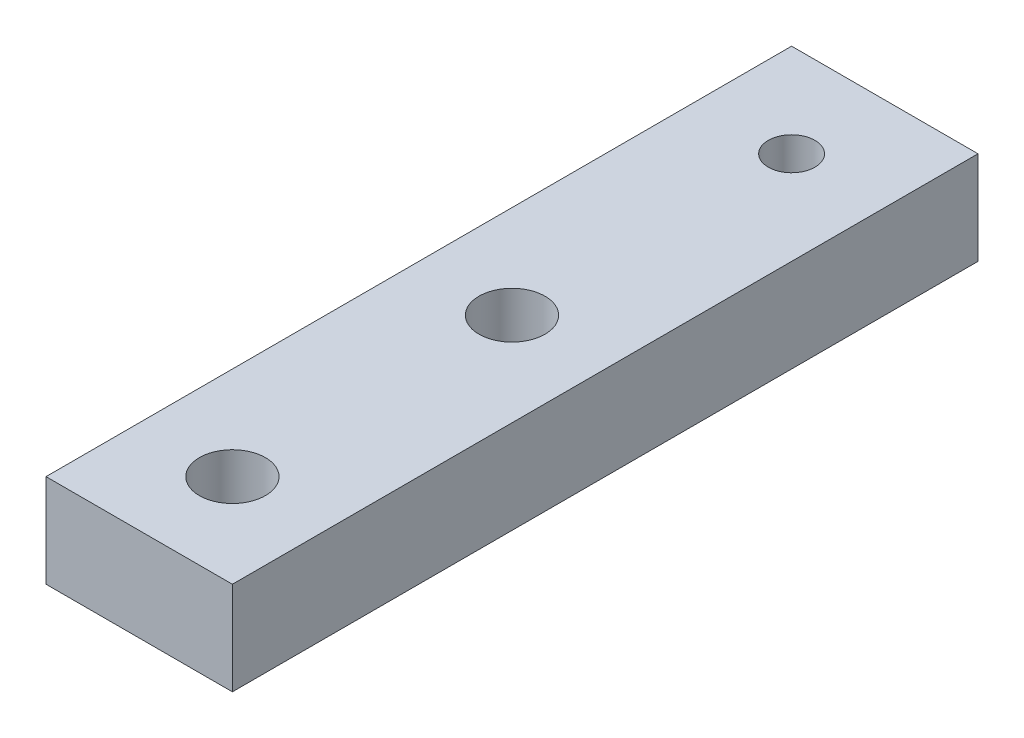
from build123d import *

# Parameters (mm, degrees)
SKETCH1_W             = 12.7
SKETCH1_H             = 50.8
BOSS_EXTRUDE1_DEPTH   = 6.35
SKETCH9_R             = 1.5875
CUT_EXTRUDE1_DEPTH    = 7.35
F_8_CLEARANCE_HOLE1_D = 4.4958


with BuildPart() as part:
    # Sketch1 → Boss-Extrude1 (new body)
    with BuildSketch(Plane(origin=(0, 0, 0), x_dir=(1, 0, 0), z_dir=(0, 1, 0))):
        with Locations((6.35, 25.4)):
            Rectangle(SKETCH1_W, SKETCH1_H)
    extrude(amount=BOSS_EXTRUDE1_DEPTH)

    # Sketch9 → Cut-Extrude1 (cut, through all)
    with BuildSketch(Plane(origin=(0, 6.35, 0), x_dir=(1, 0, 0), z_dir=(0, 1, 0))):
        with Locations(Location((6.35, 44.45, 0), (0, 0, 270))):  # turned: the seam where the file's is
            Circle(SKETCH9_R)
    extrude(amount=-CUT_EXTRUDE1_DEPTH, mode=Mode.SUBTRACT)

    # #8 Clearance Hole1 (through all)
    with Locations(Plane(origin=(0, 6.35, 0), x_dir=(1, 0, 0), z_dir=(0, 1, 0))):
        with Locations((6.35, 25.4), (6.35, 6.35)):
            Hole(F_8_CLEARANCE_HOLE1_D / 2)


solid = part.part
